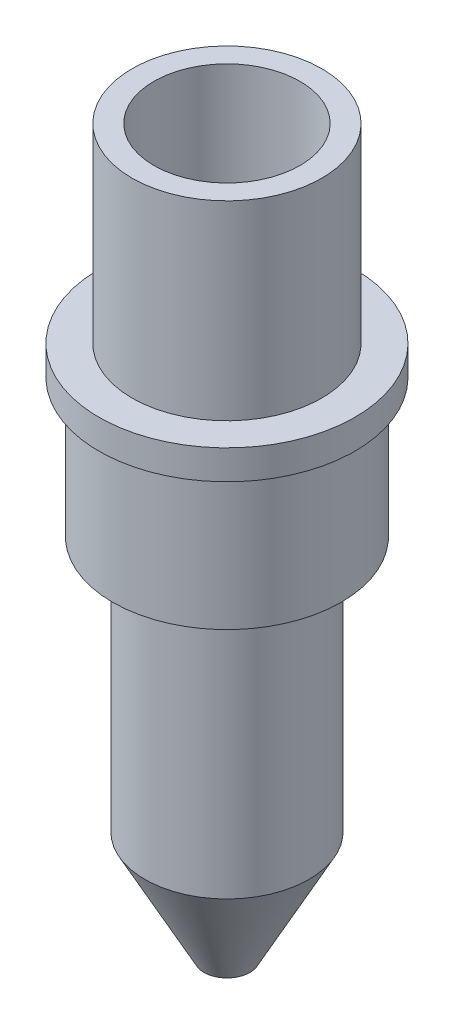
from build123d import *

# Parameters (mm, degrees)
SKETCH1_R           = 10.33
SKETCH1_R_2         = 7.95
BOSS_EXTRUDE1_DEPTH = 20.74
SKETCH2_R           = 13.94
BOSS_EXTRUDE2_DEPTH = 3.2
SKETCH3_R           = 12.44
BOSS_EXTRUDE3_DEPTH = 15
SKETCH4_R           = 8.94
BOSS_EXTRUDE4_DEPTH = 39.88
SKETCH6_R           = 2.45
CUT_EXTRUDE1_DEPTH  = 79.82
SKETCH7_R           = 5.5
CUT_EXTRUDE2_DEPTH  = 46


with BuildPart() as part:
    # Sketch1 → Boss-Extrude1 (new body)
    with BuildSketch(Plane(origin=(0, 0, 0), x_dir=(1, 0, 0), z_dir=(0, 1, 0))):
        Circle(SKETCH1_R)
        Circle(SKETCH1_R_2, mode=Mode.SUBTRACT)
    extrude(amount=BOSS_EXTRUDE1_DEPTH)

    # Sketch2 → Boss-Extrude2 (add)
    with BuildSketch(Plane.XZ):
        Circle(SKETCH2_R)
    extrude(amount=BOSS_EXTRUDE2_DEPTH)

    # Sketch3 → Boss-Extrude3 (add)
    with BuildSketch(Plane(origin=(0, -3.2, 0), x_dir=(-1, 0, 0), z_dir=(0, -1, 0))):
        Circle(SKETCH3_R)
    extrude(amount=BOSS_EXTRUDE3_DEPTH)

    # Sketch4 → Boss-Extrude4 (add)
    with BuildSketch(Plane(origin=(0, -18.2, 0), x_dir=(-1, 0, 0), z_dir=(0, -1, 0))):
        Circle(SKETCH4_R)
    extrude(amount=BOSS_EXTRUDE4_DEPTH)

    # Sketch5 → Cut-Revolve1 (revolve, cut)
    with BuildSketch(Plane(origin=(0, 0, 0), x_dir=(0, 0, -1), z_dir=(1, 0, 0))):
        Polygon((8.94, -46.08), (2.5, -58.08), (8.94, -58.08), align=None)
    revolve(axis=Axis((0, -58.08, 0), (0, 1, 0)), mode=Mode.SUBTRACT)

    # Sketch6 → Cut-Extrude1 (cut, through all)
    with BuildSketch(Plane.XZ.offset(58.08)):
        Circle(SKETCH6_R)
    extrude(amount=-CUT_EXTRUDE1_DEPTH, mode=Mode.SUBTRACT)

    # Sketch7 → Cut-Extrude2 (cut)
    with BuildSketch(Plane(origin=(0, 0, 0), x_dir=(1, 0, 0), z_dir=(0, 1, 0))):
        Circle(SKETCH7_R)
    extrude(amount=-CUT_EXTRUDE2_DEPTH, mode=Mode.SUBTRACT)


solid = part.part
